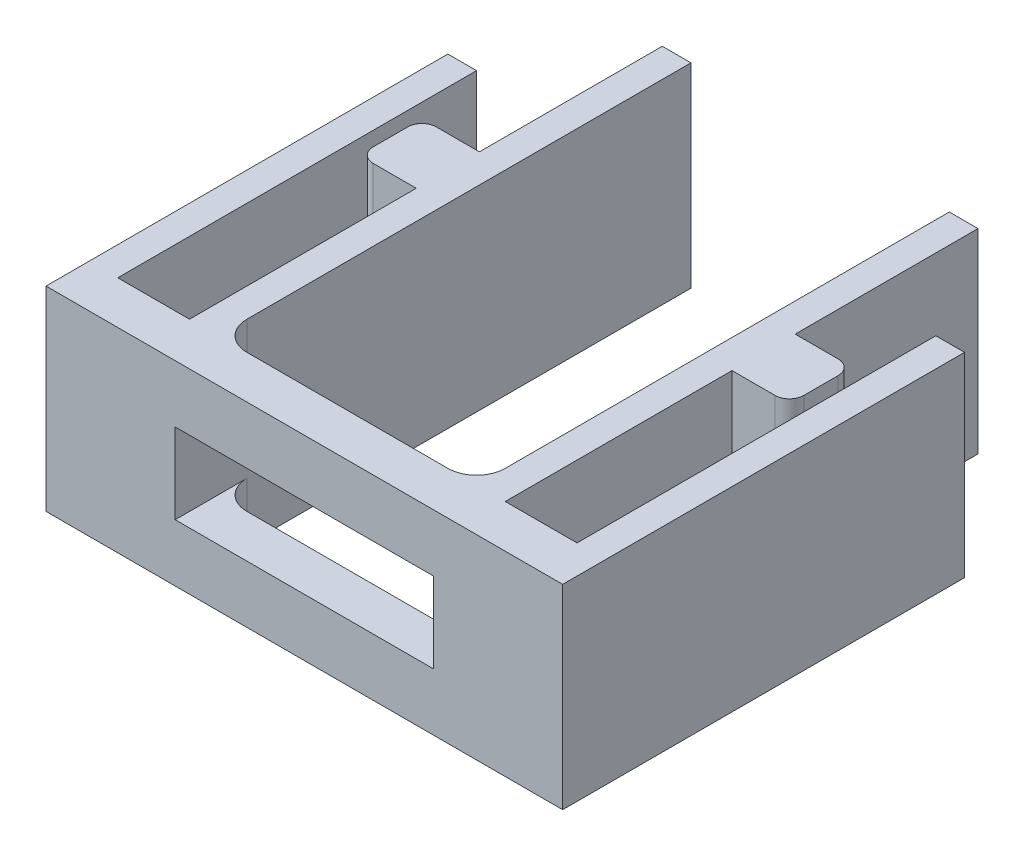
from build123d import *

# Parameters (mm, degrees)
SALIENTE_EXTRUIR1_DEPTH = 6.8
CROQUIS2_W              = 9
CROQUIS2_H              = 2.8
CORTAR_EXTRUIR1_DEPTH   = 18.969669092
REDONDEO1_R             = 0.5
REDONDEO2_R             = 0.5
REDONDEO3_R             = 0.5
REDONDEO4_R             = 0.5


with BuildPart() as part:
    # Croquis1 → Saliente-Extruir1 (new body)
    with BuildSketch(Plane(origin=(0, 0, 0), x_dir=(1, 0, 0), z_dir=(0, 1, 0))):
        with BuildLine():
            Line((0, 0), (0, 14))
            Line((0, 14), (1, 14))
            Line((1, 14), (1, 1.5))
            Line((1, 1.5), (3.5, 1.5))
            Line((3.5, 1.5), (3.5, 9.4))
            Line((3.5, 9.4), (1.5, 9.4))
            Line((1.5, 9.4), (1.5, 11.6))
            Line((1.5, 11.6), (3.5, 11.6))
            Line((3.5, 11.6), (3.5, 17.969669092))
            Line((3.5, 17.969669092), (4.5, 17.969669092))
            Line((4.5, 17.969669092), (4.5, 2.5))
            ThreePointArc((4.5, 2.5), (4.792893219, 1.792893219), (5.5, 1.5))
            Line((5.5, 1.5), (12.5, 1.5))
            ThreePointArc((12.5, 1.5), (13.207106781, 1.792893219), (13.5, 2.5))
            Line((13.5, 2.5), (13.5, 17.969669092))
            Line((13.5, 17.969669092), (14.5, 17.969669092))
            Line((14.5, 17.969669092), (14.5, 11.6))
            Line((14.5, 11.6), (16.5, 11.6))
            Line((16.5, 11.6), (16.5, 9.4))
            Line((16.5, 9.4), (14.5, 9.4))
            Line((14.5, 9.4), (14.5, 1.5))
            Line((14.5, 1.5), (17, 1.5))
            Line((17, 1.5), (17, 14))
            Line((17, 14), (18, 14))
            Line((18, 14), (18, 0))
            Line((18, 0), (0, 0))
        make_face()
    extrude(amount=SALIENTE_EXTRUIR1_DEPTH)

    # Croquis2 → Cortar-Extruir1 (cut, through all)
    with BuildSketch(Plane.XY):
        with Locations((9, 3.4)):
            Rectangle(CROQUIS2_W, CROQUIS2_H)
    extrude(amount=-CORTAR_EXTRUIR1_DEPTH, mode=Mode.SUBTRACT)

    # Redondeo1
    redondeo1_edges = [part.edges().sort_by_distance(p)[0] for p in [
        (16.5, 3.4, -11.6),
    ]]
    fillet(redondeo1_edges, radius=REDONDEO1_R)

    # Redondeo2
    redondeo2_edges = [part.edges().sort_by_distance(p)[0] for p in [
        (16.5, 3.4, -9.4),
    ]]
    fillet(redondeo2_edges, radius=REDONDEO2_R)

    # Redondeo3
    redondeo3_edges = [part.edges().sort_by_distance(p)[0] for p in [
        (1.5, 3.4, -9.4),
    ]]
    fillet(redondeo3_edges, radius=REDONDEO3_R)

    # Redondeo4
    redondeo4_edges = [part.edges().sort_by_distance(p)[0] for p in [
        (1.5, 3.4, -11.6),
    ]]
    fillet(redondeo4_edges, radius=REDONDEO4_R)


solid = part.part
